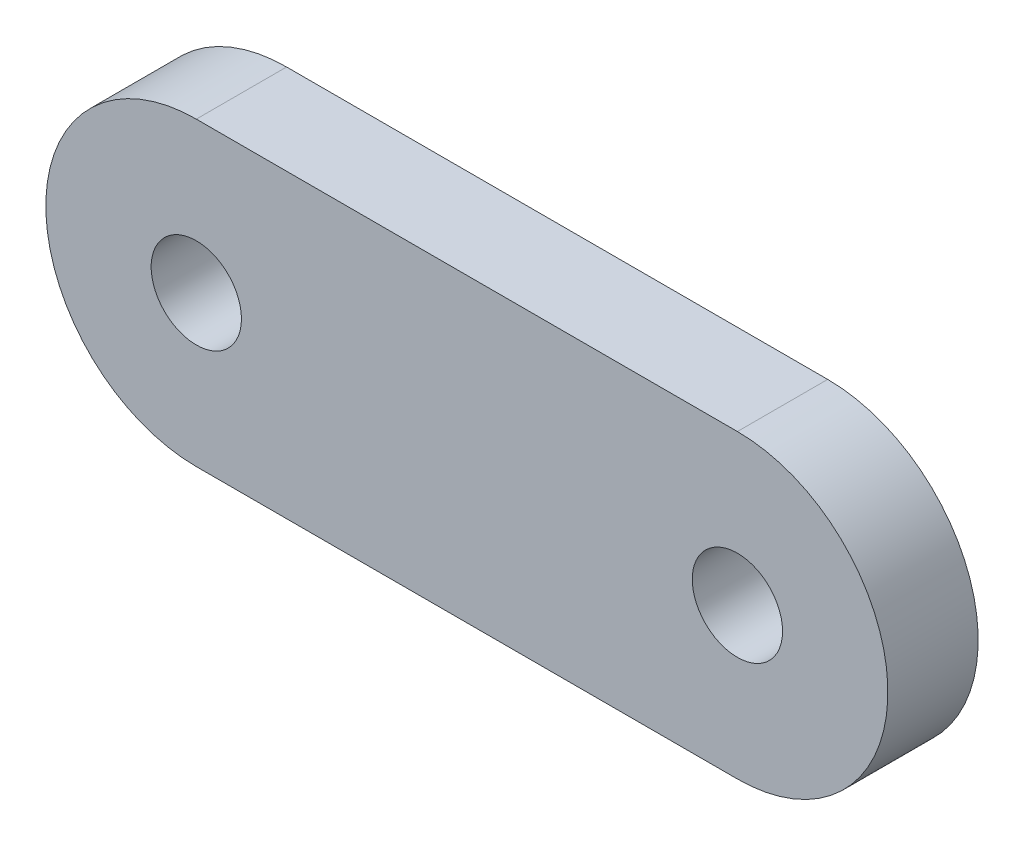
from build123d import *

# Parameters (mm, degrees)
SKETCH_1_R      = 0.75
EXTRUDE_1_DEPTH = 0.75


with BuildPart() as part:
    # 草圖1 → 填料-伸長1 (new body, symmetric)
    with BuildSketch(Plane.XY):
        with BuildLine():
            Line((-4.495, 2.5), (4.495, 2.5))
            ThreePointArc((4.495, 2.5), (6.995, 0), (4.495, -2.5))
            Line((4.495, -2.5), (-4.495, -2.5))
            ThreePointArc((-4.495, -2.5), (-6.995, 0), (-4.495, 2.5))
        make_face()
        with Locations((4.495, 0)):
            Circle(SKETCH_1_R, mode=Mode.SUBTRACT)
        with Locations((-4.495, 0)):
            Circle(SKETCH_1_R, mode=Mode.SUBTRACT)
    extrude(amount=EXTRUDE_1_DEPTH, both=True)


solid = part.part
